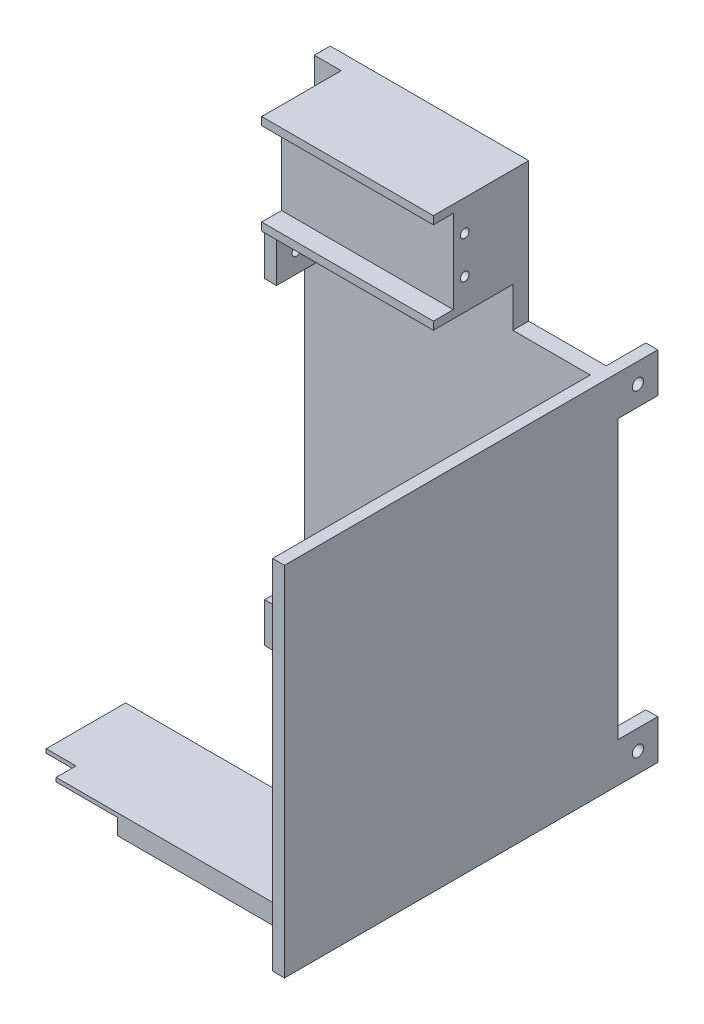
from build123d import *

# Parameters (mm, degrees)
EXTRUDE_1_DEPTH     = 4
SKETCH_3_W          = 43.235473071
SKETCH_3_H          = 2
EXTRUDE_2_DEPTH     = 20
SKETCH_4_W          = 43.235473071
SKETCH_4_H          = 21
EXTRUDE_3_DEPTH     = 15
SKETCH_8_W          = 3
SKETCH_8_H          = 10
EXTRUDE_4_DEPTH     = 10
SKETCH_10_R         = 1.4
CUT_EXTRUDE_1_DEPTH = 83
SKETCH_11_W         = 3
SKETCH_11_H         = 90
EXTRUDE_5_DEPTH     = 80
SKETCH_12_W         = 75
SKETCH_12_H         = 25
EXTRUDE_6_DEPTH     = 5
SKETCH_13_W         = 23
SKETCH_13_H         = 20
CUT_EXTRUDE_2_DEPTH = 4
CUT_EXTRUDE_3_REACH = 123
SKETCH_14_W         = 7.5
SKETCH_14_H         = 5
SKETCH_15_R         = 1.1
CUT_EXTRUDE_4_DEPTH = 10
SKETCH_17_W         = 3
SKETCH_17_H         = 10
EXTRUDE_7_DEPTH     = 10
SKETCH_18_R         = 1.1
CUT_EXTRUDE_5_DEPTH = 3
SKETCH_19_W         = 3
SKETCH_19_H         = 10
EXTRUDE_8_DEPTH     = 10
SKETCH_20_R         = 1.1
CUT_EXTRUDE_6_DEPTH = 3


with BuildPart() as part:
    # 草圖1 → 填料-伸長1 (new body)
    with BuildSketch(Plane.XY):
        Polygon((-37.5, 45), (-35, 45), (-35, 80), (15, 80), (15, 45), (37.5, 45), (37.5, -45), (-37.5, -45), align=None)
    extrude(amount=EXTRUDE_1_DEPTH)

    # 草圖3 → 填料-伸長2 (add)
    with BuildSketch(Plane.XY.offset(4)):
        with Locations((-6.617736535, 56)):
            Rectangle(SKETCH_3_W, SKETCH_3_H)
        with Locations((-6.617736535, 79)):
            Rectangle(SKETCH_3_W, SKETCH_3_H)
    extrude(amount=EXTRUDE_2_DEPTH)

    # 草圖4 → 填料-伸長3 (add)
    with BuildSketch(Plane.XY.offset(4)):
        with Locations((-6.617736535, 67.5)):
            Rectangle(SKETCH_4_W, SKETCH_4_H)
    extrude(amount=EXTRUDE_3_DEPTH)

    # 草圖8 → 填料-伸長4 (add)
    with BuildSketch(Plane(origin=(0, 0, 0), x_dir=(-1, 0, 0), z_dir=(0, 0, -1))):
        with Locations((-36, 40)):
            Rectangle(SKETCH_8_W, SKETCH_8_H)
        with Locations((36, 40)):
            Rectangle(SKETCH_8_W, SKETCH_8_H)
        with Locations((36, -40)):
            Rectangle(SKETCH_8_W, SKETCH_8_H)
        with Locations((-36, -40)):
            Rectangle(SKETCH_8_W, SKETCH_8_H)
    extrude(amount=EXTRUDE_4_DEPTH)

    # 草圖10 → 除料-伸長1 (cut)
    with BuildSketch(Plane(origin=(37.5, 0, 0), x_dir=(0, 0, -1), z_dir=(1, 0, 0))):
        with Locations((5, 40)):
            Circle(SKETCH_10_R)
        with Locations((5, -40)):
            Circle(SKETCH_10_R)
    extrude(amount=-CUT_EXTRUDE_1_DEPTH, mode=Mode.SUBTRACT)

    # 草圖11 → 填料-伸長5 (add)
    with BuildSketch(Plane.XY.offset(4)):
        with Locations((36, 0)):
            Rectangle(SKETCH_11_W, SKETCH_11_H)
    extrude(amount=EXTRUDE_5_DEPTH)

    # 草圖12 → 填料-伸長6 (add)
    with BuildSketch(Plane.XZ.offset(45)):
        with Locations((0, 61.5)):
            Rectangle(SKETCH_12_W, SKETCH_12_H)
    extrude(amount=-EXTRUDE_6_DEPTH)

    # 草圖13 → 除料-伸長2 (cut)
    with BuildSketch(Plane.XZ.offset(45)):
        with Locations((-26, 64)):
            Rectangle(SKETCH_13_W, SKETCH_13_H)
    extrude(amount=-CUT_EXTRUDE_2_DEPTH, mode=Mode.SUBTRACT)

    # 草圖14 → 除料-伸長3 (cut, up to next)
    with BuildSketch(Plane.XZ.offset(41), mode=Mode.PRIVATE) as cut_extrude_3_sk1:
        with Locations((-33.75, 71.5)):
            Rectangle(SKETCH_14_W, SKETCH_14_H)
    cut_extrude_3_tool1 = extrude(cut_extrude_3_sk1.sketch, amount=-CUT_EXTRUDE_3_REACH, mode=Mode.PRIVATE) & part.part
    add(cut_extrude_3_tool1.solids().sort_by_distance((-33.75, -41, 71.5))[0], mode=Mode.SUBTRACT)

    # 草圖15 → 除料-伸長4 (cut)
    with BuildSketch(Plane(origin=(15, 0, 0), x_dir=(0, 0, -1), z_dir=(1, 0, 0))):
        with Locations((-16.1, 72.2)):
            Circle(SKETCH_15_R)
        with Locations((-16.1, 62.8)):
            Circle(SKETCH_15_R)
    extrude(amount=-CUT_EXTRUDE_4_DEPTH, mode=Mode.SUBTRACT)

    # 草圖17 → 填料-伸長7 (add)
    with BuildSketch(Plane.XY.offset(4)):
        with Locations((-36, 40)):
            Rectangle(SKETCH_17_W, SKETCH_17_H)
    extrude(amount=EXTRUDE_7_DEPTH)

    # 草圖18 → 除料-伸長5 (cut)
    with BuildSketch(Plane.ZY.offset(37.5)):
        with Locations((9, 40)):
            Circle(SKETCH_18_R)
    extrude(amount=-CUT_EXTRUDE_5_DEPTH, mode=Mode.SUBTRACT)

    # 草圖19 → 填料-伸長8 (add)
    with BuildSketch(Plane.XY.offset(4)):
        with Locations((-36, -40)):
            Rectangle(SKETCH_19_W, SKETCH_19_H)
    extrude(amount=EXTRUDE_8_DEPTH)

    # 草圖20 → 除料-伸長6 (cut)
    with BuildSketch(Plane.ZY.offset(37.5)):
        with Locations((9, -40)):
            Circle(SKETCH_20_R)
    extrude(amount=-CUT_EXTRUDE_6_DEPTH, mode=Mode.SUBTRACT)


solid = part.part
